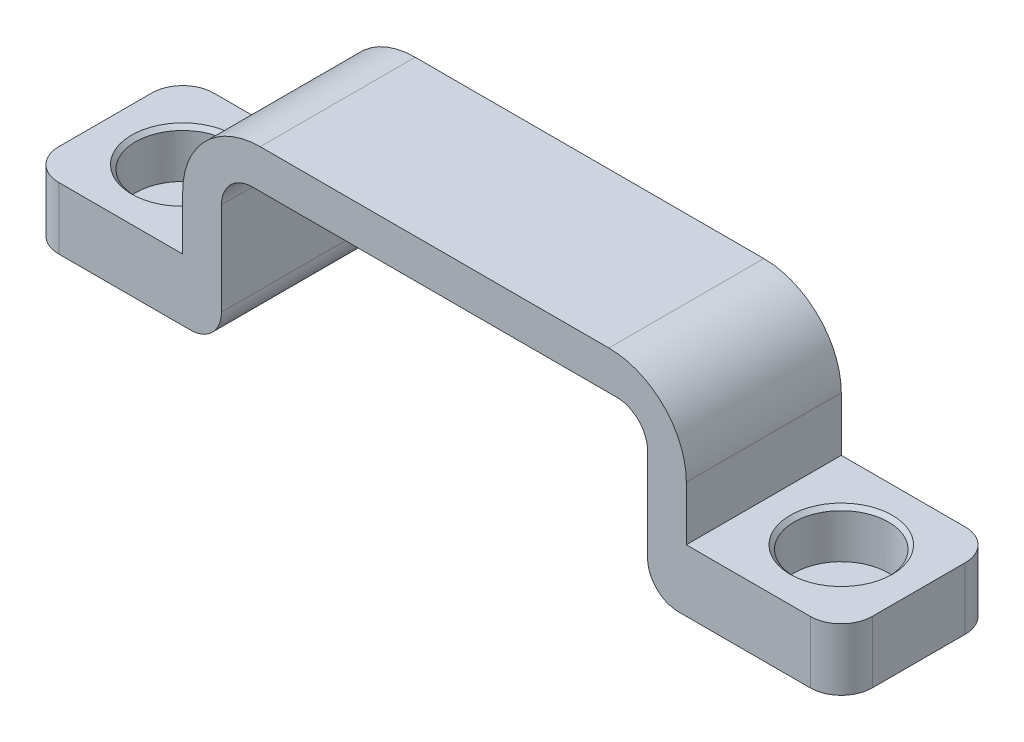
from build123d import *

# Parameters (mm, degrees)
BOSS_EXTRUDE1_DEPTH = 5
FILLET1_R           = 2
FILLET2_R           = 5
FILLET3_R           = 2
FILLET4_R           = 2
SKETCH3_R           = 3.05
CUT_EXTRUDE1_DEPTH  = 3.1
CHAMFER1_SIZE       = 0.25


with BuildPart() as part:
    # Sketch1 → Boss-Extrude1 (new body, symmetric)
    with BuildSketch(Plane.XY):
        Polygon((-16.25, 2.5), (16.25, 2.5), (16.25, -6), (26.25, -6), (26.25, -10), (16.25, -10), (13.75, -10), (13.75, 0), (-13.75, 0), (-13.75, -10), (-16.25, -10), (-26.25, -10), (-26.25, -6), (-16.25, -6), align=None)
    extrude(amount=BOSS_EXTRUDE1_DEPTH, both=True)

    # Fillet1
    fillet1_edges = [part.edges().sort_by_distance(p)[0] for p in [
        (13.75, 0, 0),
        (-13.75, 0, 0),
    ]]
    fillet(fillet1_edges, radius=FILLET1_R)

    # Fillet2
    fillet2_edges = [part.edges().sort_by_distance(p)[0] for p in [
        (-16.25, 2.5, 0),
        (16.25, 2.5, 0),
    ]]
    fillet(fillet2_edges, radius=FILLET2_R)

    # Fillet3
    fillet3_edges = [part.edges().sort_by_distance(p)[0] for p in [
        (26.25, -8, -5),
        (-26.25, -8, -5),
        (-26.25, -8, 5),
        (26.25, -8, 5),
    ]]
    fillet(fillet3_edges, radius=FILLET3_R)

    # Fillet4
    fillet4_edges = [part.edges().sort_by_distance(p)[0] for p in [
        (13.75, -10, 0),
        (-13.75, -10, 0),
    ]]
    fillet(fillet4_edges, radius=FILLET4_R)

    # Sketch3 → Cut-Extrude1 (cut)
    with BuildSketch(Plane(origin=(0, -6, 0), x_dir=(1, 0, 0), z_dir=(0, 1, 0))):
        with Locations((21.25, 0)):
            Circle(SKETCH3_R)
        with Locations((-21.25, 0)):
            Circle(SKETCH3_R)
    extrude(amount=-CUT_EXTRUDE1_DEPTH, mode=Mode.SUBTRACT)

    # Chamfer1
    chamfer1_edges = [part.edges().sort_by_distance(p)[0] for p in [
        (18.2, -6, 0),
        (-24.3, -6, 0),
    ]]
    chamfer(chamfer1_edges, length=CHAMFER1_SIZE)


solid = part.part
